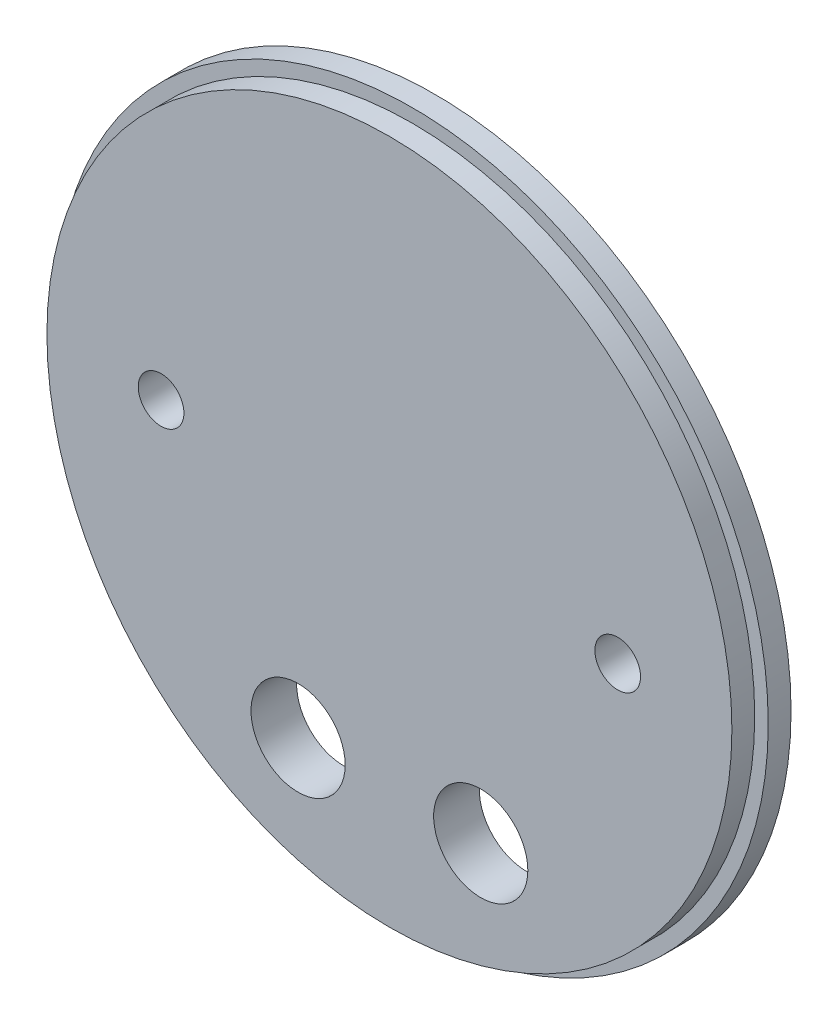
from build123d import *

# Parameters (mm, degrees)
SKETCH1_R           = 49.5046
BOSS_EXTRUDE1_DEPTH = 3.175
SKETCH2_R           = 47.625
BOSS_EXTRUDE2_DEPTH = 3.175
SKETCH3_R           = 6.5484375
SKETCH3_R_2         = 3.175
CUT_EXTRUDE1_DEPTH  = 7.35


with BuildPart() as part:
    # Sketch1 → Boss-Extrude1 (new body)
    with BuildSketch(Plane.XY):
        Circle(SKETCH1_R)
    extrude(amount=BOSS_EXTRUDE1_DEPTH)

    # Sketch2 → Boss-Extrude2 (add)
    with BuildSketch(Plane.XY.offset(3.175)):
        Circle(SKETCH2_R)
    extrude(amount=BOSS_EXTRUDE2_DEPTH)

    # Sketch3 → Cut-Extrude1 (cut, through all)
    with BuildSketch(Plane.XY.offset(6.35)):
        with Locations((-12.7, -31.166793627)):
            Circle(SKETCH3_R)
        with Locations((12.7, -31.166793627)):
            Circle(SKETCH3_R)
        with Locations((-31.75, 0)):
            Circle(SKETCH3_R_2)
        with Locations((31.75, 0)):
            Circle(SKETCH3_R_2)
    extrude(amount=-CUT_EXTRUDE1_DEPTH, mode=Mode.SUBTRACT)


solid = part.part
